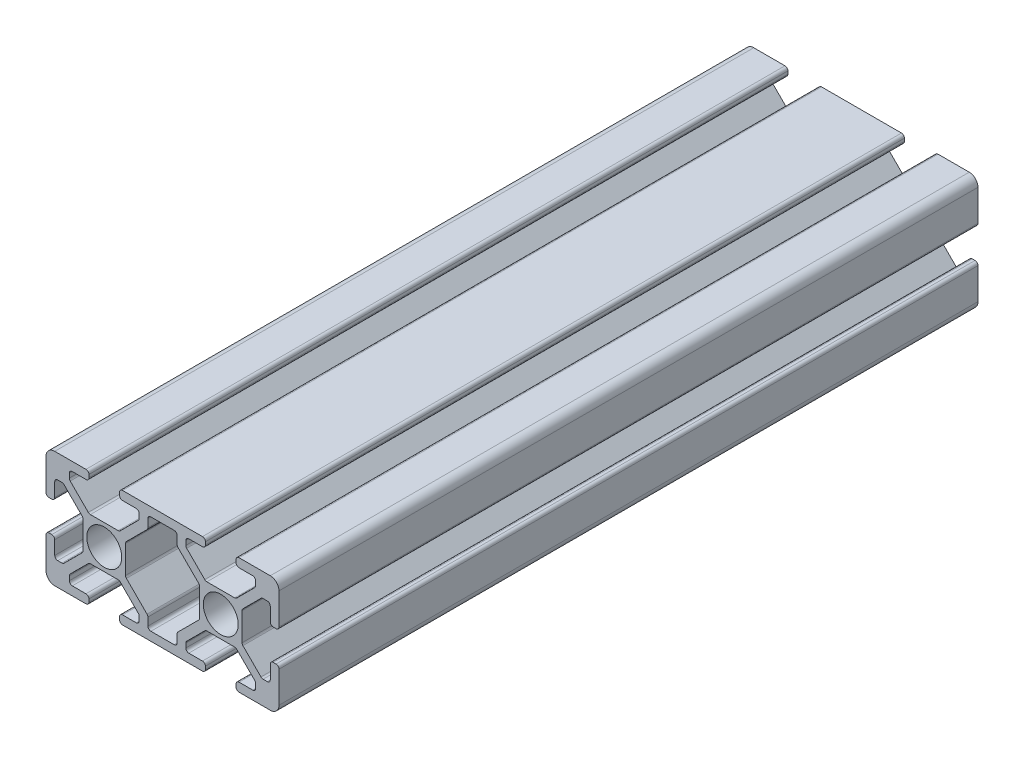
from build123d import *

# Parameters (mm, degrees)
SKETCH1_R      = 3
EXTRUDE1_DEPTH = 120


with BuildPart() as part:
    # Sketch1 → Extrude1 (new body)
    with BuildSketch(Plane.XY):
        with BuildLine():
            Line((-22.383919339, -3.655), (-17.616080661, -3.655))
            ThreePointArc((-17.616080661, -3.655), (-17.421677478, -3.693669197), (-17.256870417, -3.803789755))
            Line((-17.256870417, -3.803789755), (-14.153789755, -6.906870417))
            ThreePointArc((-14.153789755, -6.906870417), (-14.043669197, -7.071677478), (-14.005, -7.266080661))
            Line((-14.005, -7.266080661), (-14.005, -7.992))
            ThreePointArc((-14.005, -7.992), (-14.153789755, -8.351210245), (-14.513, -8.5))
            Line((-14.513, -8.5), (-16.862, -8.5))
            ThreePointArc((-16.862, -8.5), (-17.221210245, -8.648789755), (-17.37, -9.008))
            Line((-17.37, -9.008), (-17.37, -9.492))
            ThreePointArc((-17.37, -9.492), (-17.221210245, -9.851210245), (-16.862, -10))
            Line((-16.862, -10), (-3.138, -10))
            ThreePointArc((-3.138, -10), (-2.778789755, -9.851210245), (-2.63, -9.492))
            Line((-2.63, -9.492), (-2.63, -9.008))
            ThreePointArc((-2.63, -9.008), (-2.778789755, -8.648789755), (-3.138, -8.5))
            Line((-3.138, -8.5), (-5.487, -8.5))
            ThreePointArc((-5.487, -8.5), (-5.846210245, -8.351210245), (-5.995, -7.992))
            Line((-5.995, -7.992), (-5.995, -7.266080661))
            ThreePointArc((-5.995, -7.266080661), (-5.956330803, -7.071677478), (-5.846210245, -6.906870417))
            Line((-5.846210245, -6.906870417), (-2.743129583, -3.803789755))
            ThreePointArc((-2.743129583, -3.803789755), (-2.578322522, -3.693669197), (-2.383919339, -3.655))
            Line((-2.383919339, -3.655), (2.383919339, -3.655))
            ThreePointArc((2.383919339, -3.655), (2.578322522, -3.693669197), (2.743129583, -3.803789755))
            Line((2.743129583, -3.803789755), (5.846210245, -6.906870417))
            ThreePointArc((5.846210245, -6.906870417), (5.956330803, -7.071677478), (5.995, -7.266080661))
            Line((5.995, -7.266080661), (5.995, -7.992))
            ThreePointArc((5.995, -7.992), (5.846210245, -8.351210245), (5.487, -8.5))
            Line((5.487, -8.5), (3.138, -8.5))
            ThreePointArc((3.138, -8.5), (2.778789755, -8.648789755), (2.63, -9.008))
            Line((2.63, -9.008), (2.63, -9.492))
            ThreePointArc((2.63, -9.492), (2.778789755, -9.851210245), (3.138, -10))
            Line((3.138, -10), (8.5, -10))
            ThreePointArc((8.5, -10), (9.560660172, -9.560660172), (10, -8.5))
            Line((10, -8.5), (10, -3.138))
            ThreePointArc((10, -3.138), (9.851210245, -2.778789755), (9.492, -2.63))
            Line((9.492, -2.63), (9.008, -2.63))
            ThreePointArc((9.008, -2.63), (8.648789755, -2.778789755), (8.5, -3.138))
            Line((8.5, -3.138), (8.5, -5.487))
            ThreePointArc((8.5, -5.487), (8.351210245, -5.846210245), (7.992, -5.995))
            Line((7.992, -5.995), (7.266080661, -5.995))
            ThreePointArc((7.266080661, -5.995), (7.071677478, -5.956330803), (6.906870417, -5.846210245))
            Line((6.906870417, -5.846210245), (3.803789755, -2.743129583))
            ThreePointArc((3.803789755, -2.743129583), (3.693669197, -2.578322522), (3.655, -2.383919339))
            Line((3.655, -2.383919339), (3.655, 2.383919339))
            ThreePointArc((3.655, 2.383919339), (3.693669197, 2.578322522), (3.803789755, 2.743129583))
            Line((3.803789755, 2.743129583), (6.906870417, 5.846210245))
            ThreePointArc((6.906870417, 5.846210245), (7.071677478, 5.956330803), (7.266080661, 5.995))
            Line((7.266080661, 5.995), (7.992, 5.995))
            ThreePointArc((7.992, 5.995), (8.351210245, 5.846210245), (8.5, 5.487))
            Line((8.5, 5.487), (8.5, 3.138))
            ThreePointArc((8.5, 3.138), (8.648789755, 2.778789755), (9.008, 2.63))
            Line((9.008, 2.63), (9.492, 2.63))
            ThreePointArc((9.492, 2.63), (9.851210245, 2.778789755), (10, 3.138))
            Line((10, 3.138), (10, 8.5))
            ThreePointArc((10, 8.5), (9.560660172, 9.560660172), (8.5, 10))
            Line((8.5, 10), (3.138, 10))
            ThreePointArc((3.138, 10), (2.778789755, 9.851210245), (2.63, 9.492))
            Line((2.63, 9.492), (2.63, 9.008))
            ThreePointArc((2.63, 9.008), (2.778789755, 8.648789755), (3.138, 8.5))
            Line((3.138, 8.5), (5.487, 8.5))
            ThreePointArc((5.487, 8.5), (5.846210245, 8.351210245), (5.995, 7.992))
            Line((5.995, 7.992), (5.995, 7.266080661))
            ThreePointArc((5.995, 7.266080661), (5.956330803, 7.071677478), (5.846210245, 6.906870417))
            Line((5.846210245, 6.906870417), (2.743129583, 3.803789755))
            ThreePointArc((2.743129583, 3.803789755), (2.578322522, 3.693669197), (2.383919339, 3.655))
            Line((2.383919339, 3.655), (-2.383919339, 3.655))
            ThreePointArc((-2.383919339, 3.655), (-2.578322522, 3.693669197), (-2.743129583, 3.803789755))
            Line((-2.743129583, 3.803789755), (-5.846210245, 6.906870417))
            ThreePointArc((-5.846210245, 6.906870417), (-5.956330803, 7.071677478), (-5.995, 7.266080661))
            Line((-5.995, 7.266080661), (-5.995, 7.992))
            ThreePointArc((-5.995, 7.992), (-5.846210245, 8.351210245), (-5.487, 8.5))
            Line((-5.487, 8.5), (-3.138, 8.5))
            ThreePointArc((-3.138, 8.5), (-2.778789755, 8.648789755), (-2.63, 9.008))
            Line((-2.63, 9.008), (-2.63, 9.492))
            ThreePointArc((-2.63, 9.492), (-2.778789755, 9.851210245), (-3.138, 10))
            Line((-3.138, 10), (-16.862, 10))
            ThreePointArc((-16.862, 10), (-17.221210245, 9.851210245), (-17.37, 9.492))
            Line((-17.37, 9.492), (-17.37, 9.008))
            ThreePointArc((-17.37, 9.008), (-17.221210245, 8.648789755), (-16.862, 8.5))
            Line((-16.862, 8.5), (-14.513, 8.5))
            ThreePointArc((-14.513, 8.5), (-14.153789755, 8.351210245), (-14.005, 7.992))
            Line((-14.005, 7.992), (-14.005, 7.266080661))
            ThreePointArc((-14.005, 7.266080661), (-14.043669197, 7.071677478), (-14.153789755, 6.906870417))
            Line((-14.153789755, 6.906870417), (-17.256870417, 3.803789755))
            ThreePointArc((-17.256870417, 3.803789755), (-17.421677478, 3.693669197), (-17.616080661, 3.655))
            Line((-17.616080661, 3.655), (-22.383919339, 3.655))
            ThreePointArc((-22.383919339, 3.655), (-22.578322522, 3.693669197), (-22.743129583, 3.803789755))
            Line((-22.743129583, 3.803789755), (-25.846210245, 6.906870417))
            ThreePointArc((-25.846210245, 6.906870417), (-25.956330803, 7.071677478), (-25.995, 7.266080661))
            Line((-25.995, 7.266080661), (-25.995, 7.992))
            ThreePointArc((-25.995, 7.992), (-25.846210245, 8.351210245), (-25.487, 8.5))
            Line((-25.487, 8.5), (-23.138, 8.5))
            ThreePointArc((-23.138, 8.5), (-22.778789755, 8.648789755), (-22.63, 9.008))
            Line((-22.63, 9.008), (-22.63, 9.492))
            ThreePointArc((-22.63, 9.492), (-22.778789755, 9.851210245), (-23.138, 10))
            Line((-23.138, 10), (-28.5, 10))
            ThreePointArc((-28.5, 10), (-29.560660172, 9.560660172), (-30, 8.5))
            Line((-30, 8.5), (-30, 3.138))
            ThreePointArc((-30, 3.138), (-29.851210245, 2.778789755), (-29.492, 2.63))
            Line((-29.492, 2.63), (-29.008, 2.63))
            ThreePointArc((-29.008, 2.63), (-28.648789755, 2.778789755), (-28.5, 3.138))
            Line((-28.5, 3.138), (-28.5, 5.487))
            ThreePointArc((-28.5, 5.487), (-28.351210245, 5.846210245), (-27.992, 5.995))
            Line((-27.992, 5.995), (-27.266080661, 5.995))
            ThreePointArc((-27.266080661, 5.995), (-27.071677478, 5.956330803), (-26.906870417, 5.846210245))
            Line((-26.906870417, 5.846210245), (-23.803789755, 2.743129583))
            ThreePointArc((-23.803789755, 2.743129583), (-23.693669197, 2.578322522), (-23.655, 2.383919339))
            Line((-23.655, 2.383919339), (-23.655, -2.383919339))
            ThreePointArc((-23.655, -2.383919339), (-23.693669197, -2.578322522), (-23.803789755, -2.743129583))
            Line((-23.803789755, -2.743129583), (-26.906870417, -5.846210245))
            ThreePointArc((-26.906870417, -5.846210245), (-27.071677478, -5.956330803), (-27.266080661, -5.995))
            Line((-27.266080661, -5.995), (-27.992, -5.995))
            ThreePointArc((-27.992, -5.995), (-28.351210245, -5.846210245), (-28.5, -5.487))
            Line((-28.5, -5.487), (-28.5, -3.138))
            ThreePointArc((-28.5, -3.138), (-28.648789755, -2.778789755), (-29.008, -2.63))
            Line((-29.008, -2.63), (-29.492, -2.63))
            ThreePointArc((-29.492, -2.63), (-29.851210245, -2.778789755), (-30, -3.138))
            Line((-30, -3.138), (-30, -8.5))
            ThreePointArc((-30, -8.5), (-29.560660172, -9.560660172), (-28.5, -10))
            Line((-28.5, -10), (-23.138, -10))
            ThreePointArc((-23.138, -10), (-22.778789755, -9.851210245), (-22.63, -9.492))
            Line((-22.63, -9.492), (-22.63, -9.008))
            ThreePointArc((-22.63, -9.008), (-22.778789755, -8.648789755), (-23.138, -8.5))
            Line((-23.138, -8.5), (-25.487, -8.5))
            ThreePointArc((-25.487, -8.5), (-25.846210245, -8.351210245), (-25.995, -7.992))
            Line((-25.995, -7.992), (-25.995, -7.266080661))
            ThreePointArc((-25.995, -7.266080661), (-25.956330803, -7.071677478), (-25.846210245, -6.906870417))
            Line((-25.846210245, -6.906870417), (-22.743129583, -3.803789755))
            ThreePointArc((-22.743129583, -3.803789755), (-22.578322522, -3.693669197), (-22.383919339, -3.655))
        make_face()
        with Locations((-20, 0)):
            Circle(SKETCH1_R, mode=Mode.SUBTRACT)
        Circle(SKETCH1_R, mode=Mode.SUBTRACT)
        with BuildLine():
            Line((-12.505, -7.992), (-12.505, -6.644760318))
            ThreePointArc((-12.505, -6.644760318), (-12.543669197, -6.450357134), (-12.653789755, -6.285550073))
            Line((-12.653789755, -6.285550073), (-16.196210245, -2.743129583))
            ThreePointArc((-16.196210245, -2.743129583), (-16.306330803, -2.578322522), (-16.345, -2.383919339))
            Line((-16.345, -2.383919339), (-16.345, 2.383919339))
            ThreePointArc((-16.345, 2.383919339), (-16.306330803, 2.578322522), (-16.196210245, 2.743129583))
            Line((-16.196210245, 2.743129583), (-12.653789755, 6.285550073))
            ThreePointArc((-12.653789755, 6.285550073), (-12.543669197, 6.450357134), (-12.505, 6.644760318))
            Line((-12.505, 6.644760318), (-12.505, 7.992))
            ThreePointArc((-12.505, 7.992), (-12.356210245, 8.351210245), (-11.997, 8.5))
            Line((-11.997, 8.5), (-8.003, 8.5))
            ThreePointArc((-8.003, 8.5), (-7.643789755, 8.351210245), (-7.495, 7.992))
            Line((-7.495, 7.992), (-7.495, 6.644760318))
            ThreePointArc((-7.495, 6.644760318), (-7.456330803, 6.450357134), (-7.346210245, 6.285550073))
            Line((-7.346210245, 6.285550073), (-3.803789755, 2.743129583))
            ThreePointArc((-3.803789755, 2.743129583), (-3.693669197, 2.578322522), (-3.655, 2.383919339))
            Line((-3.655, 2.383919339), (-3.655, -2.383919339))
            ThreePointArc((-3.655, -2.383919339), (-3.693669197, -2.578322522), (-3.803789755, -2.743129583))
            Line((-3.803789755, -2.743129583), (-7.346210245, -6.285550073))
            ThreePointArc((-7.346210245, -6.285550073), (-7.456330803, -6.450357134), (-7.495, -6.644760318))
            Line((-7.495, -6.644760318), (-7.495, -7.992))
            ThreePointArc((-7.495, -7.992), (-7.643789755, -8.351210245), (-8.003, -8.5))
            Line((-8.003, -8.5), (-11.997, -8.5))
            ThreePointArc((-11.997, -8.5), (-12.356210245, -8.351210245), (-12.505, -7.992))
        make_face(mode=Mode.SUBTRACT)
    extrude(amount=-EXTRUDE1_DEPTH)


solid = part.part
